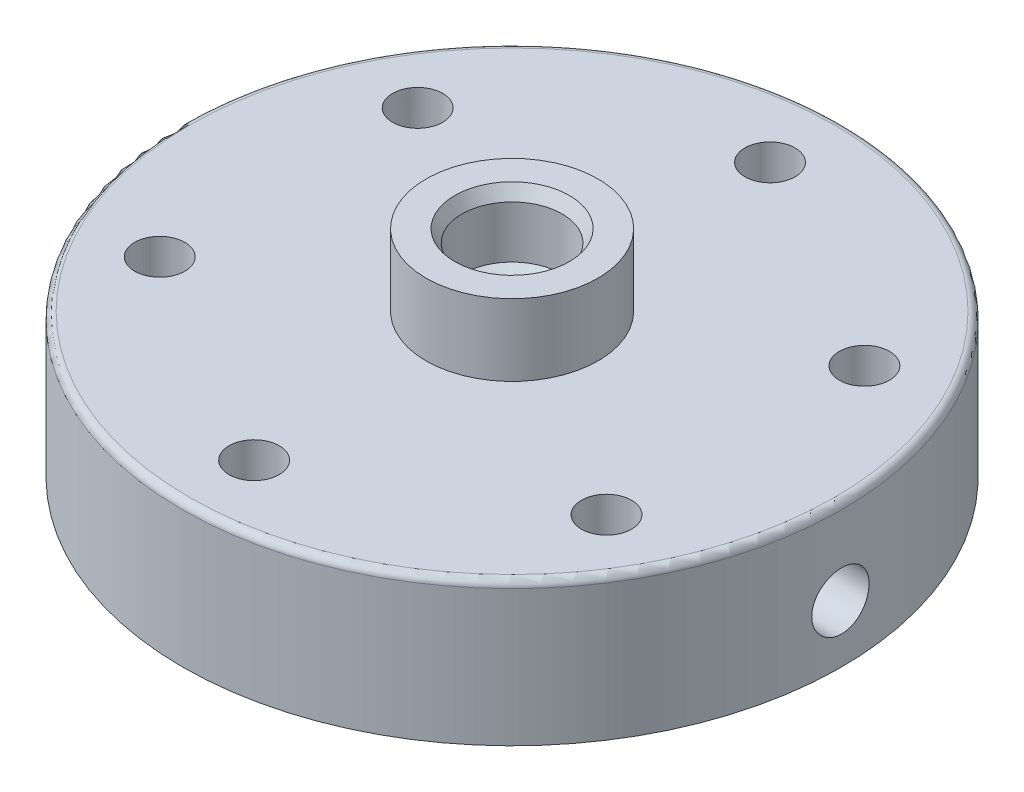
from build123d import *

# Parameters (mm, degrees)
SKETCH3_R             = 46
SKETCH3_R_2           = 3.5
BOSS_EXTRUDE2_DEPTH   = 20
FILLET1_R             = 1
SKETCH4_R             = 12
BOSS_EXTRUDE3_DEPTH   = 10
SKETCH5_R             = 33
CUT_EXTRUDE1_DEPTH    = 14
SKETCH6_R             = 2.5
CUT_EXTRUDE2_DEPTH    = 6
SKETCH7_R             = 7
CUT_EXTRUDE3_DEPTH    = 10
CHAMFER1_SIZE         = 1
CHAMFER1_SIZE2        = 1.732050808
CHAMFER1_PART_2_SIZE  = 1
CHAMFER1_PART_2_SIZE2 = 1.732050808
SKETCH8_R             = 4
CUT_EXTRUDE4_DEPTH    = 47.0000001


with BuildPart() as part:
    # Sketch3 → Boss-Extrude2 (new body)
    with BuildSketch(Plane(origin=(0, 0, 0), x_dir=(1, 0, 0), z_dir=(0, 1, 0))):
        Circle(SKETCH3_R)
        with Locations((0, 36)):
            Circle(SKETCH3_R_2, mode=Mode.SUBTRACT)
        with Locations((31.176914536, 18)):
            Circle(SKETCH3_R_2, mode=Mode.SUBTRACT)
        with Locations((31.176914536, -18)):
            Circle(SKETCH3_R_2, mode=Mode.SUBTRACT)
        with Locations((0, -36)):
            Circle(SKETCH3_R_2, mode=Mode.SUBTRACT)
        with Locations((-31.176914536, -18)):
            Circle(SKETCH3_R_2, mode=Mode.SUBTRACT)
        with Locations((-31.176914536, 18)):
            Circle(SKETCH3_R_2, mode=Mode.SUBTRACT)
    extrude(amount=BOSS_EXTRUDE2_DEPTH)

    # Fillet1
    fillet1_edges = [part.edges().sort_by_distance(p)[0] for p in [
        (-46, 20, 0),
    ]]
    fillet(fillet1_edges, radius=FILLET1_R)

    # Sketch4 → Boss-Extrude3 (add)
    with BuildSketch(Plane(origin=(0, 20, 0), x_dir=(1, 0, 0), z_dir=(0, 1, 0))):
        Circle(SKETCH4_R)
    extrude(amount=BOSS_EXTRUDE3_DEPTH)

    # Sketch5 → Cut-Extrude1 (cut)
    with BuildSketch(Plane.XZ):
        Circle(SKETCH5_R)
    extrude(amount=-CUT_EXTRUDE1_DEPTH, mode=Mode.SUBTRACT)

    # Sketch6 → Cut-Extrude2 (cut)
    with BuildSketch(Plane.XZ.offset(-14)):
        Circle(SKETCH6_R)
    extrude(amount=-CUT_EXTRUDE2_DEPTH, mode=Mode.SUBTRACT)

    # Sketch7 → Cut-Extrude3 (cut)
    with BuildSketch(Plane(origin=(0, 30, 0), x_dir=(1, 0, 0), z_dir=(0, 1, 0))):
        Circle(SKETCH7_R)
    extrude(amount=-CUT_EXTRUDE3_DEPTH, mode=Mode.SUBTRACT)

    # Chamfer1
    chamfer1_edges = [part.edges().sort_by_distance(p)[0] for p in [
        (-7, 20, 0),
    ]]
    chamfer1_side = [part.faces().sort_by_distance(p)[0] for p in [
        (-7, 25, 0),
    ]]
    chamfer(chamfer1_edges, length=CHAMFER1_SIZE, length2=CHAMFER1_SIZE2, reference=chamfer1_side[0])

    # Chamfer1 part 2
    chamfer1_part_2_edges = [part.edges().sort_by_distance(p)[0] for p in [
        (-7, 30, 0),
    ]]
    chamfer1_part_2_side = [part.faces().sort_by_distance(p)[0] for p in [
        (-11.660588745, 30, 0),
    ]]
    chamfer(chamfer1_part_2_edges, length=CHAMFER1_PART_2_SIZE, length2=CHAMFER1_PART_2_SIZE2, reference=chamfer1_part_2_side[0])

    # Sketch8 → Cut-Extrude4 (cut, through all)
    with BuildSketch(Plane(origin=(0, 0, 0), x_dir=(0, 0, -1), z_dir=(1, 0, 0))):
        with Locations((0, 8)):
            Circle(SKETCH8_R)
    extrude(amount=CUT_EXTRUDE4_DEPTH, mode=Mode.SUBTRACT)


solid = part.part
